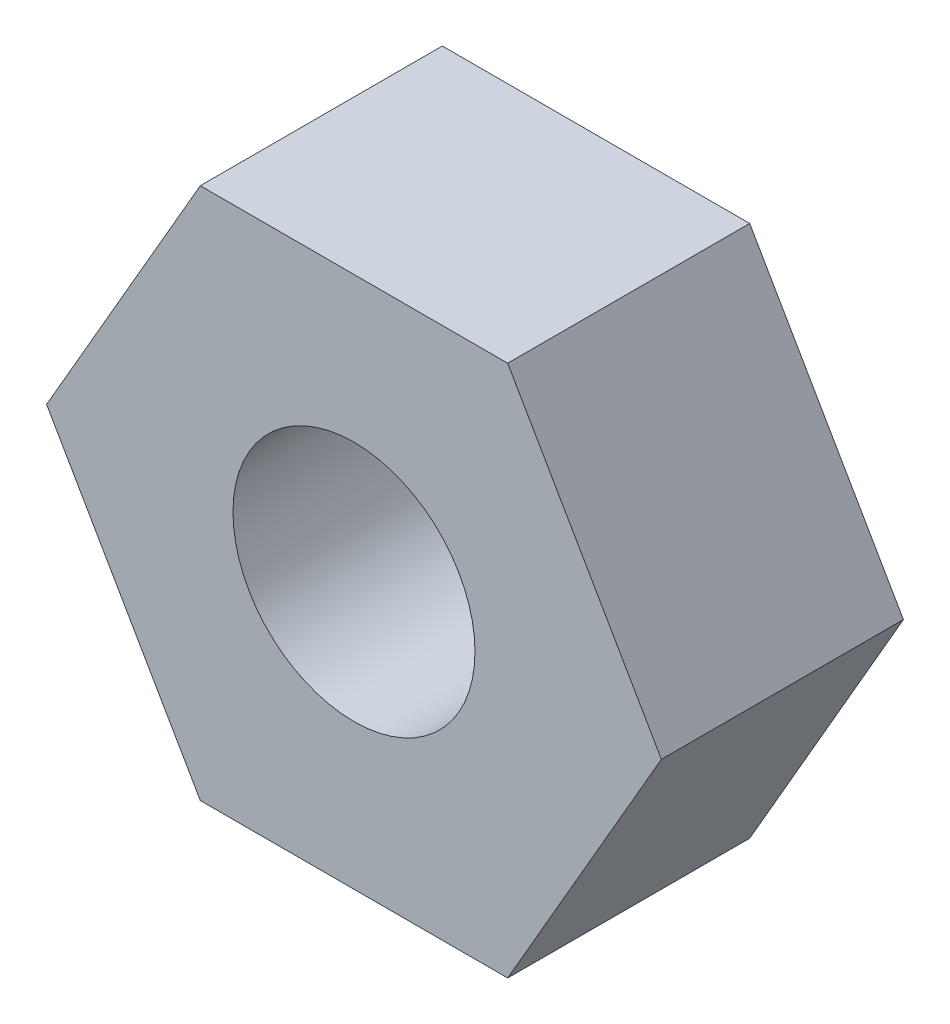
from build123d import *

# Parameters (mm, degrees)
ESQUISSE1_R        = 1.25
BOSS_EXTRU_1_DEPTH = 2.5


with BuildPart() as part:
    # Esquisse1 → Boss.-Extru.1 (new body)
    with BuildSketch(Plane.XY):
        Polygon((-1.58771324, 2.75), (1.58771324, 2.75), (3.175426481, 0), (1.58771324, -2.75), (-1.58771324, -2.75), (-3.175426481, 0), align=None)
        Circle(ESQUISSE1_R, mode=Mode.SUBTRACT)
    extrude(amount=BOSS_EXTRU_1_DEPTH)


solid = part.part
